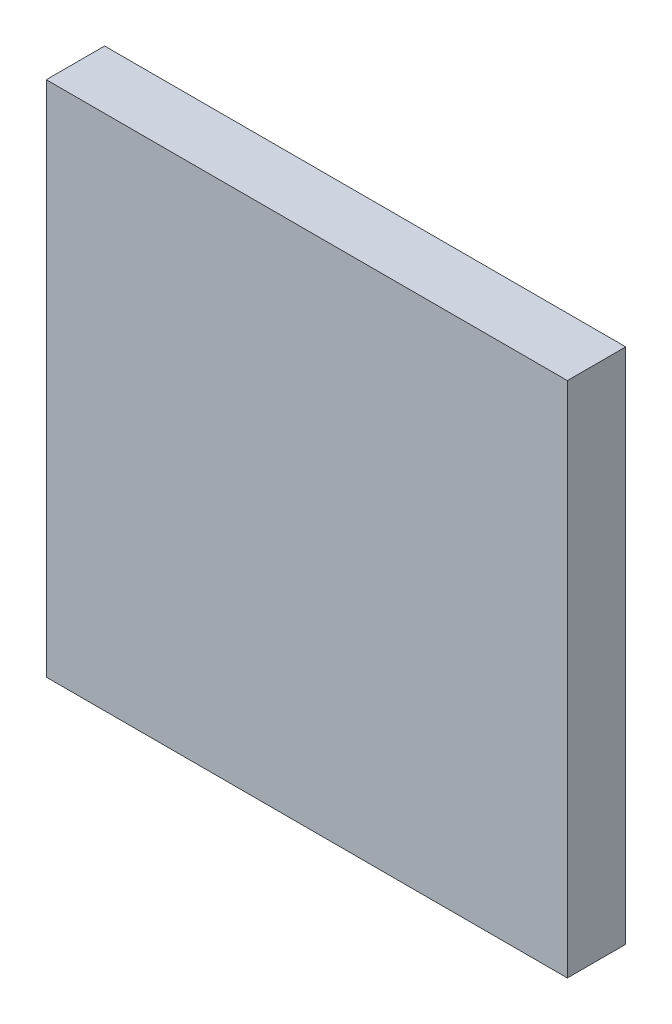
from build123d import *

# Parameters (mm, degrees)
SKETCH1_W               = 8.927
SKETCH1_H               = 8.8635
COMPONENT_OUTLINE_DEPTH = 1


with BuildPart() as part:
    # Sketch1 → Component_Outline (new body)
    with BuildSketch(Plane.XY):
        with Locations((0, 0.03175)):
            Rectangle(SKETCH1_W, SKETCH1_H)
    extrude(amount=COMPONENT_OUTLINE_DEPTH)


solid = part.part
